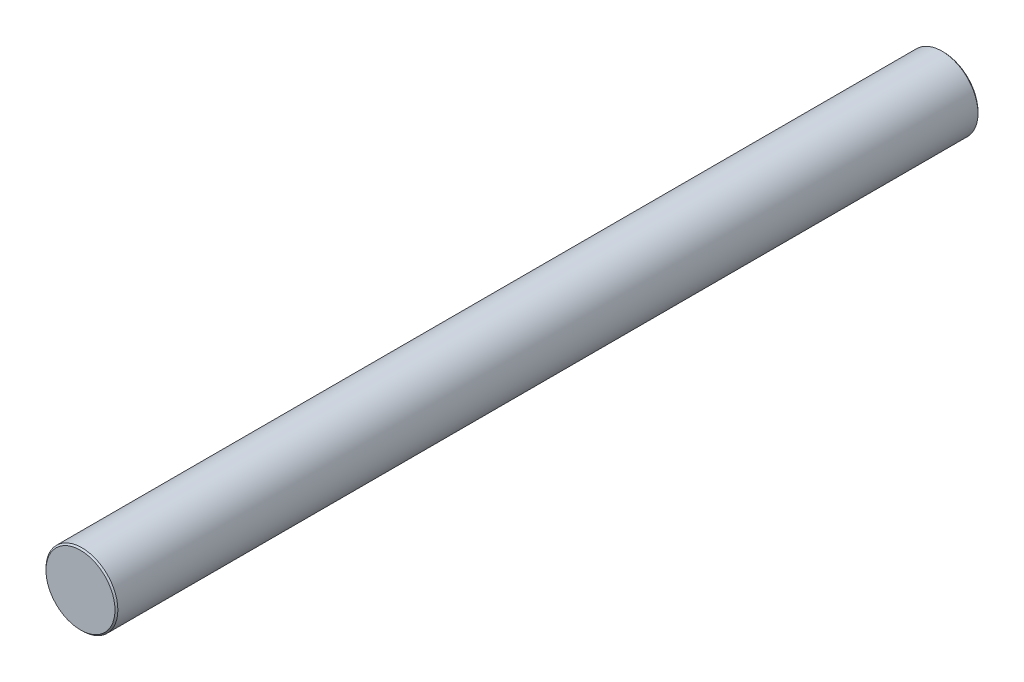
from build123d import *

# Parameters (mm, degrees)
SKETCH3_R                = 12.7
BOSS_EXTRUDE1_DEPTH      = 152.4
BOSS_EXTRUDE1_DEPTH_BACK = 152.4
CHAMFER1_SIZE            = 0.508


with BuildPart() as part:
    # Sketch3 → Boss-Extrude1 (new body, two sides)
    with BuildSketch(Plane.XY) as boss_extrude1_sk:
        Circle(SKETCH3_R)
    extrude(amount=BOSS_EXTRUDE1_DEPTH)
    extrude(boss_extrude1_sk.sketch, amount=-BOSS_EXTRUDE1_DEPTH_BACK)

    # Chamfer1
    chamfer1_edges = [part.edges().sort_by_distance(p)[0] for p in [
        (-12.7, 0, -152.4),
        (-12.7, 0, 152.4),
    ]]
    chamfer(chamfer1_edges, length=CHAMFER1_SIZE)


solid = part.part
